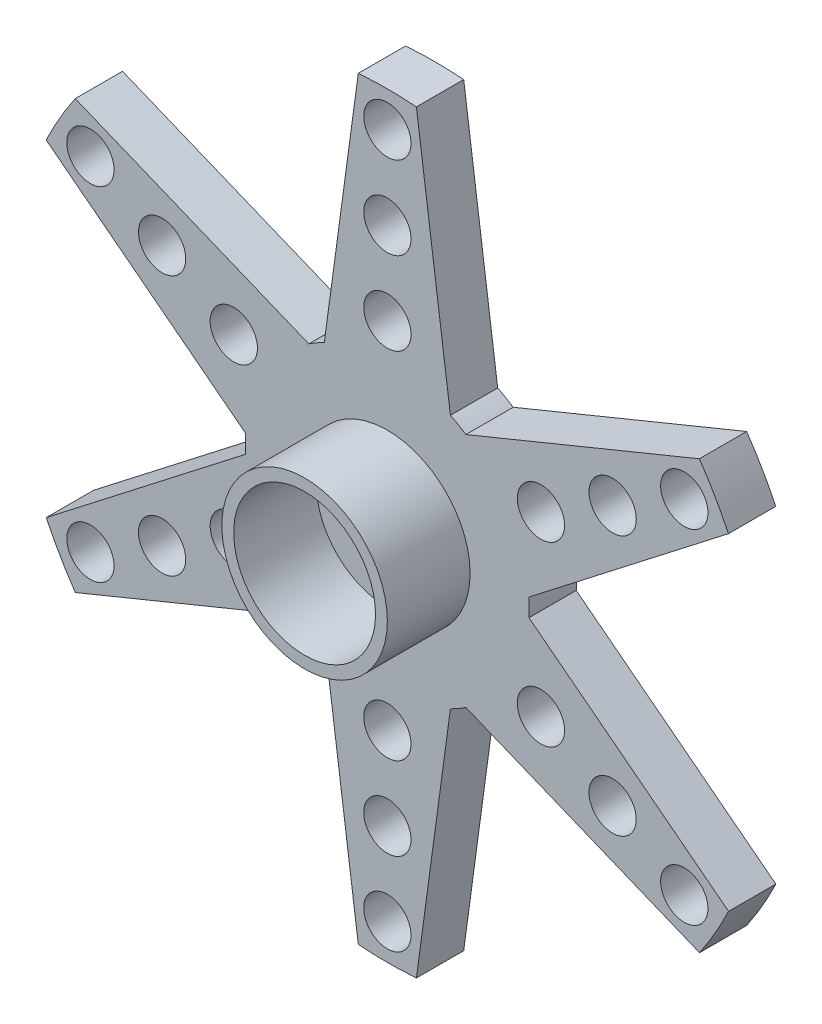
from build123d import *

# Parameters (mm, degrees)
SKETCH1_R           = 1
BOSS_EXTRUDE3_DEPTH = 2
SKETCH2_R           = 1.75
CUT_EXTRUDE2_DEPTH  = 2
SKETCH3_R           = 3.5
SKETCH3_R_2         = 3
BOSS_EXTRUDE4_DEPTH = 3.5


with BuildPart() as part:
    # Sketch1 → Boss-Extrude3 (new body)
    with BuildSketch(Plane.XY):
        with BuildLine():
            ThreePointArc((1.229444159, 15.952694665), (0, 16), (-1.229444159, 15.952694665))
            Line((-1.229444159, 15.952694665), (-2.666890983, 5.374727201))
            ThreePointArc((-2.666890983, 5.374727201), (-3, 5.196152423), (-3.321204803, 4.996958941))
            Line((-3.321204803, 4.996958941), (-13.200716759, 9.041077207))
            ThreePointArc((-13.200716759, 9.041077207), (-13.856406461, 8), (-14.430160918, 6.911617458))
            Line((-14.430160918, 6.911617458), (-5.988095786, 0.37776826))
            ThreePointArc((-5.988095786, 0.37776826), (-5.999999995, -0.000251411), (-5.988064107, -0.378270083))
            Line((-5.988064107, -0.378270083), (-14.426795427, -6.918639585))
            ThreePointArc((-14.426795427, -6.918639585), (-13.85251149, -8.006742498), (-13.196315379, -9.04750023))
            Line((-13.196315379, -9.04750023), (-3.320786342, -4.997237044))
            ThreePointArc((-3.320786342, -4.997237044), (-2.999782432, -5.196278029), (-2.666890983, -5.374727201))
            Line((-2.666890983, -5.374727201), (-1.229444159, -15.952694665))
            ThreePointArc((-1.229444159, -15.952694665), (0, -16), (1.229444159, -15.952694665))
            Line((1.229444159, -15.952694665), (2.666890983, -5.374727201))
            ThreePointArc((2.666890983, -5.374727201), (3, -5.196152423), (3.321204803, -4.996958941))
            Line((3.321204803, -4.996958941), (13.200716759, -9.041077207))
            ThreePointArc((13.200716759, -9.041077207), (13.856406461, -8), (14.430160918, -6.911617458))
            Line((14.430160918, -6.911617458), (5.988095786, -0.37776826))
            ThreePointArc((5.988095786, -0.37776826), (5.999999995, 0.000251411), (5.988064107, 0.378270083))
            Line((5.988064107, 0.378270083), (14.426795427, 6.918639585))
            ThreePointArc((14.426795427, 6.918639585), (13.85251149, 8.006742498), (13.196315379, 9.04750023))
            Line((13.196315379, 9.04750023), (3.320786342, 4.997237044))
            ThreePointArc((3.320786342, 4.997237044), (2.999782432, 5.196278029), (2.666890983, 5.374727201))
            Line((2.666890983, 5.374727201), (1.229444159, 15.952694665))
        make_face()
        with Locations((0, 7.5)):
            Circle(SKETCH1_R, mode=Mode.SUBTRACT)
        with Locations((0, 11)):
            Circle(SKETCH1_R, mode=Mode.SUBTRACT)
        with Locations((0, 14.5)):
            Circle(SKETCH1_R, mode=Mode.SUBTRACT)
        with Locations((-6.495190528, 3.75)):
            Circle(SKETCH1_R, mode=Mode.SUBTRACT)
        with Locations((-12.557368355, 7.25)):
            Circle(SKETCH1_R, mode=Mode.SUBTRACT)
        with Locations((-9.526279442, 5.5)):
            Circle(SKETCH1_R, mode=Mode.SUBTRACT)
        with Locations((12.557368355, 7.25)):
            Circle(SKETCH1_R, mode=Mode.SUBTRACT)
        with Locations((6.495190528, 3.75)):
            Circle(SKETCH1_R, mode=Mode.SUBTRACT)
        with Locations((9.526279442, 5.5)):
            Circle(SKETCH1_R, mode=Mode.SUBTRACT)
        with Locations((-6.495190528, -3.75)):
            Circle(SKETCH1_R, mode=Mode.SUBTRACT)
        with Locations((-12.557368355, -7.25)):
            Circle(SKETCH1_R, mode=Mode.SUBTRACT)
        with Locations((-9.526279442, -5.5)):
            Circle(SKETCH1_R, mode=Mode.SUBTRACT)
        with Locations((12.557368355, -7.25)):
            Circle(SKETCH1_R, mode=Mode.SUBTRACT)
        with Locations((6.495190528, -3.75)):
            Circle(SKETCH1_R, mode=Mode.SUBTRACT)
        with Locations((9.526279442, -5.5)):
            Circle(SKETCH1_R, mode=Mode.SUBTRACT)
        with Locations((0, -7.5)):
            Circle(SKETCH1_R, mode=Mode.SUBTRACT)
        with Locations((0, -14.5)):
            Circle(SKETCH1_R, mode=Mode.SUBTRACT)
        with Locations((0, -11)):
            Circle(SKETCH1_R, mode=Mode.SUBTRACT)
    extrude(amount=BOSS_EXTRUDE3_DEPTH)

    # Sketch2 → Cut-Extrude2 (cut)
    with BuildSketch(Plane.XY.offset(2)):
        Circle(SKETCH2_R)
    extrude(amount=-CUT_EXTRUDE2_DEPTH, mode=Mode.SUBTRACT)

    # Sketch3 → Boss-Extrude4 (add)
    with BuildSketch(Plane.XY.offset(2)):
        Circle(SKETCH3_R)
        Circle(SKETCH3_R_2, mode=Mode.SUBTRACT)
    extrude(amount=BOSS_EXTRUDE4_DEPTH)


solid = part.part
